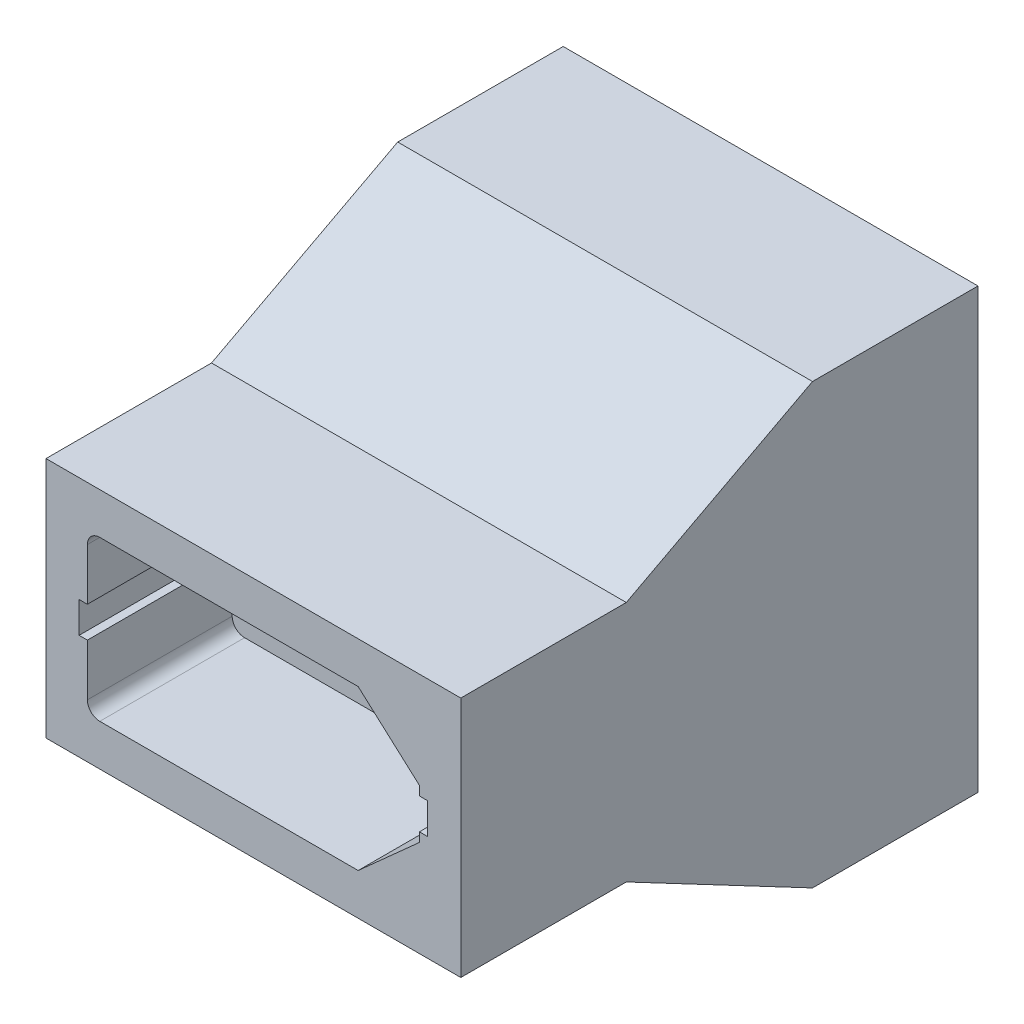
from build123d import *

# Parameters (mm, degrees)
SKETCH1_W           = 20.05
SKETCH1_H           = 21.2
BOSS_EXTRUDE1_DEPTH = 7
SKETCH2_W           = 20.05
SKETCH2_H           = 21.2
BOSS_EXTRUDE2_DEPTH = 1
SKETCH3_W           = 20.05
SKETCH3_H           = 11.7
BOSS_EXTRUDE3_DEPTH = 7
SKETCH4_W           = 20.05
SKETCH4_H           = 11.7
BOSS_EXTRUDE4_DEPTH = 1
BOSS_EXTRUDE5_DEPTH = 20.05
BOSS_EXTRUDE6_DEPTH = 1
BOSS_EXTRUDE7_DEPTH = 1


with BuildPart() as part:
    # Sketch1 → Boss-Extrude1 (new body)
    with BuildSketch(Plane.XY):
        with Locations((1.45, 4.75)):
            Rectangle(SKETCH1_W, SKETCH1_H)
        with BuildLine():
            Line((-5.975, 3.85), (6.51326417, 3.85))
            Line((6.51326417, 3.85), (9.475, 1.194650635))
            Line((9.475, 1.194650635), (9.475, 0.75))
            Line((9.475, 0.75), (9.875, 0.75))
            Line((9.875, 0.75), (9.875, -0.75))
            Line((9.875, -0.75), (9.475, -0.75))
            Line((9.475, -0.75), (9.475, -1.194650635))
            Line((9.475, -1.194650635), (6.51326417, -3.85))
            Line((6.51326417, -3.85), (-5.975, -3.85))
            ThreePointArc((-5.975, -3.85), (-6.399264069, -3.674264069), (-6.575, -3.25))
            Line((-6.575, -3.25), (-6.575, -0.75))
            Line((-6.575, -0.75), (-6.975, -0.75))
            Line((-6.975, -0.75), (-6.975, 0.75))
            Line((-6.975, 0.75), (-6.575, 0.75))
            Line((-6.575, 0.75), (-6.575, 3.25))
            ThreePointArc((-6.575, 3.25), (-6.399264069, 3.674264069), (-5.975, 3.85))
        make_face(mode=Mode.SUBTRACT)
        with BuildLine():
            Line((-5.975, 13.35), (6.51326417, 13.35))
            Line((6.51326417, 13.35), (9.475, 10.694650635))
            Line((9.475, 10.694650635), (9.475, 10.25))
            Line((9.475, 10.25), (9.875, 10.25))
            Line((9.875, 10.25), (9.875, 8.75))
            Line((9.875, 8.75), (9.475, 8.75))
            Line((9.475, 8.75), (9.475, 8.305349365))
            Line((9.475, 8.305349365), (6.51326417, 5.65))
            Line((6.51326417, 5.65), (-5.975, 5.65))
            ThreePointArc((-5.975, 5.65), (-6.399264069, 5.825735931), (-6.575, 6.25))
            Line((-6.575, 6.25), (-6.575, 8.75))
            Line((-6.575, 8.75), (-6.975, 8.75))
            Line((-6.975, 8.75), (-6.975, 10.25))
            Line((-6.975, 10.25), (-6.575, 10.25))
            Line((-6.575, 10.25), (-6.575, 12.75))
            ThreePointArc((-6.575, 12.75), (-6.399264069, 13.174264069), (-5.975, 13.35))
        make_face(mode=Mode.SUBTRACT)
    extrude(amount=-BOSS_EXTRUDE1_DEPTH)

    # Sketch2 → Boss-Extrude2 (add)
    with BuildSketch(Plane.XY):
        with Locations((1.45, 4.75)):
            Rectangle(SKETCH2_W, SKETCH2_H)
        Polygon((6.0923583, 2.75), (-5.475, 2.75), (-5.475, -2.75), (6.0923583, -2.75), (8.375, -0.703493649), (8.375, 0.703493649), align=None, mode=Mode.SUBTRACT)
        Polygon((6.0923583, 12.25), (-5.475, 12.25), (-5.475, 6.75), (6.0923583, 6.75), (8.375, 8.796506351), (8.375, 10.203493649), align=None, mode=Mode.SUBTRACT)
    extrude(amount=BOSS_EXTRUDE2_DEPTH)



with BuildPart() as body_2:
    # Sketch3 → Boss-Extrude3 (new body)
    with BuildSketch(Plane(origin=(0, 0, 11), x_dir=(-1, 0, 0), z_dir=(0, 0, -1))):
        with Locations((-1.45, 4.75)):
            Rectangle(SKETCH3_W, SKETCH3_H)
        with BuildLine():
            Line((6.975, 4), (6.575, 4))
            Line((6.575, 4), (6.575, 1.5))
            ThreePointArc((6.575, 1.5), (6.399264069, 1.075735931), (5.975, 0.9))
            Line((5.975, 0.9), (-6.51326417, 0.9))
            Line((-6.51326417, 0.9), (-9.475, 3.555349365))
            Line((-9.475, 3.555349365), (-9.475, 4))
            Line((-9.475, 4), (-9.875, 4))
            Line((-9.875, 4), (-9.875, 5.5))
            Line((-9.875, 5.5), (-9.475, 5.5))
            Line((-9.475, 5.5), (-9.475, 5.944650635))
            Line((-9.475, 5.944650635), (-6.51326417, 8.6))
            Line((-6.51326417, 8.6), (5.975, 8.6))
            ThreePointArc((5.975, 8.6), (6.399264069, 8.424264069), (6.575, 8))
            Line((6.575, 8), (6.575, 5.5))
            Line((6.575, 5.5), (6.975, 5.5))
            Line((6.975, 5.5), (6.975, 4))
        make_face(mode=Mode.SUBTRACT)
    extrude(amount=-BOSS_EXTRUDE3_DEPTH)

    # Sketch4 → Boss-Extrude4 (add)
    with BuildSketch(Plane(origin=(0, 0, 11), x_dir=(-1, 0, 0), z_dir=(0, 0, -1))):
        with Locations((-1.45, 4.75)):
            Rectangle(SKETCH4_W, SKETCH4_H)
        Polygon((-6.0923583, 2), (5.475, 2), (5.475, 7.5), (-6.0923583, 7.5), (-8.375, 5.453493649), (-8.375, 4.046506351), align=None, mode=Mode.SUBTRACT)
    extrude(amount=BOSS_EXTRUDE4_DEPTH)


with BuildPart() as part_1:
    add(part.part)

    add(body_2.part)  # Boss-Extrude5 merges body 2
    # Sketch5 → Boss-Extrude5 (add)
    with BuildSketch(Plane(origin=(11.475, 0, 0), x_dir=(0, 0, -1), z_dir=(1, 0, 0))):
        Polygon((-10, -1.1), (-1, -5.85), (-1, -4.85), (-10, -0.1), align=None)
        Polygon((-10, 9.6), (-1, 14.35), (-1, 15.35), (-10, 10.6), align=None)
    extrude(amount=-BOSS_EXTRUDE5_DEPTH)

    # Sketch6 → Boss-Extrude6 (add)
    with BuildSketch(Plane(origin=(11.475, 0, 0), x_dir=(0, 0, -1), z_dir=(1, 0, 0))):
        Polygon((-10, 9.6), (-1, 14.35), (-1, -4.85), (-10, -0.1), align=None)
    extrude(amount=-BOSS_EXTRUDE6_DEPTH)

    # Sketch7 → Boss-Extrude7 (add)
    with BuildSketch(Plane.ZY.offset(8.575)):
        Polygon((1, -4.85), (1, 14.35), (10, 9.6), (10, -0.1), align=None)
    extrude(amount=-BOSS_EXTRUDE7_DEPTH)


solid = part_1.part
